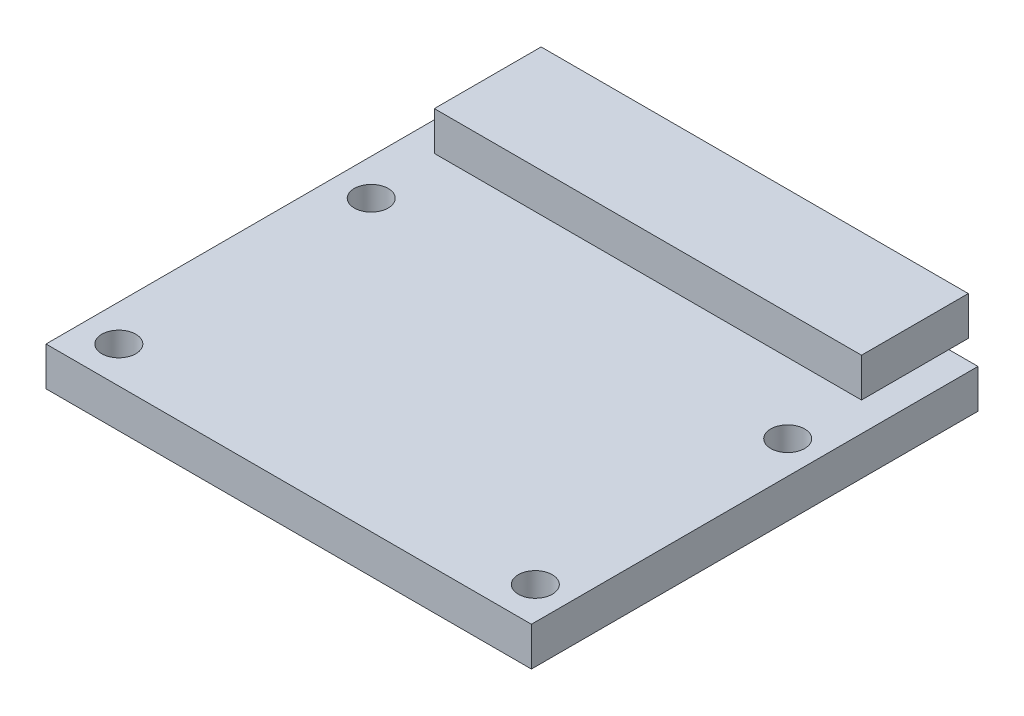
from build123d import *

# Parameters (mm, degrees)
CROQUIS1_W              = 25
CROQUIS1_H              = 23
SALIENTE_EXTRUIR1_DEPTH = 2
CROQUIS2_W              = 8.5
CROQUIS2_H              = 8.5
SALIENTE_EXTRUIR2_DEPTH = 3
CROQUIS3_R              = 3.75
SALIENTE_EXTRUIR3_DEPTH = 3
CROQUIS4_R              = 0.875
CORTAR_EXTRUIR1_DEPTH   = 3
CROQUIS5_W              = 22
CROQUIS5_H              = 5.5
SALIENTE_EXTRUIR4_DEPTH = 2


with BuildPart() as part:
    # Croquis1 → Saliente-Extruir1 (new body)
    with BuildSketch(Plane(origin=(0, 0, 0), x_dir=(1, 0, 0), z_dir=(0, 1, 0))):
        Rectangle(CROQUIS1_W, CROQUIS1_H)
    extrude(amount=SALIENTE_EXTRUIR1_DEPTH)

    # Croquis2 → Saliente-Extruir2 (add)
    with BuildSketch(Plane.XZ):
        with Locations((0, -1.75)):
            Rectangle(CROQUIS2_W, CROQUIS2_H)
    extrude(amount=SALIENTE_EXTRUIR2_DEPTH)

    # Croquis3 → Saliente-Extruir3 (add)
    with BuildSketch(Plane.XZ.offset(3)):
        with Locations((0, -1.75)):
            Circle(CROQUIS3_R)
    extrude(amount=SALIENTE_EXTRUIR3_DEPTH)

    # Croquis4 → Cortar-Extruir1 (cut)
    with BuildSketch(Plane.XZ):
        with Locations((-10.625, 9.625)):
            Circle(CROQUIS4_R)
        with Locations((10.825, 9.625)):
            Circle(CROQUIS4_R)
        with Locations((10.825, -3.375)):
            Circle(CROQUIS4_R)
        with Locations((-10.625, -3.375)):
            Circle(CROQUIS4_R)
    extrude(amount=-CORTAR_EXTRUIR1_DEPTH, mode=Mode.SUBTRACT)

    # Croquis5 → Saliente-Extruir4 (add)
    with BuildSketch(Plane(origin=(0, 2, 0), x_dir=(1, 0, 0), z_dir=(0, 1, 0))):
        with Locations((0, 9.75)):
            Rectangle(CROQUIS5_W, CROQUIS5_H)
    extrude(amount=SALIENTE_EXTRUIR4_DEPTH)


solid = part.part
